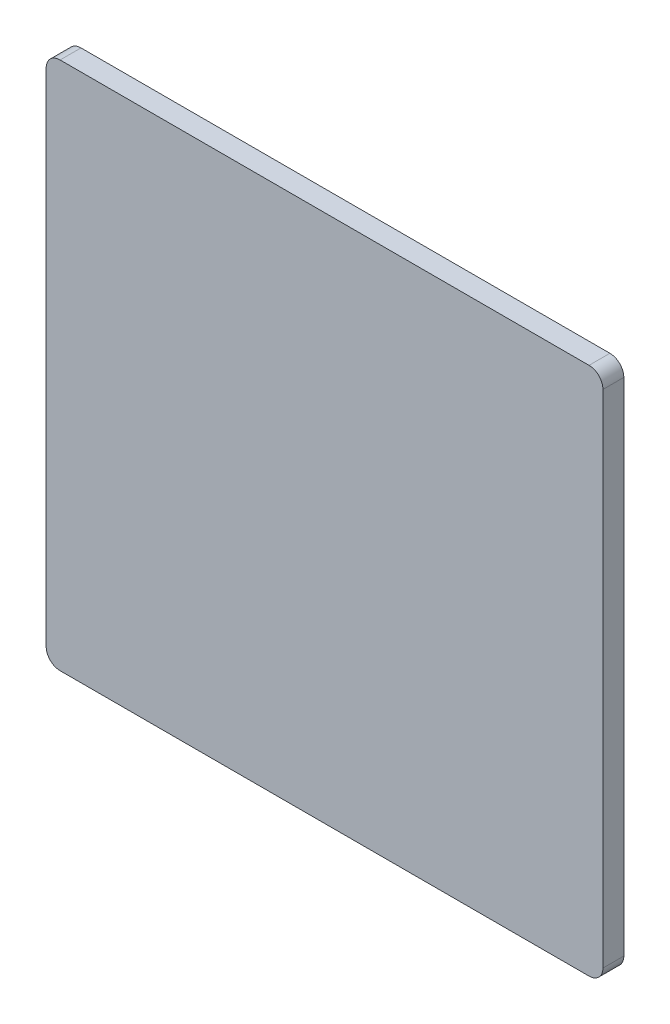
from build123d import *

# Parameters (mm, degrees)
SKETCH1_W           = 254
SKETCH1_H           = 241.3
BOSS_EXTRUDE1_DEPTH = 9.525
FILLET1_R           = 6.35


with BuildPart() as part:
    # Sketch1 → Boss-Extrude1 (new body)
    with BuildSketch(Plane.XY):
        Rectangle(SKETCH1_W, SKETCH1_H)
    extrude(amount=BOSS_EXTRUDE1_DEPTH)

    # Fillet1
    fillet1_edges = [part.edges().sort_by_distance(p)[0] for p in [
        (127, -120.65, 4.7625),
        (-127, -120.65, 4.7625),
        (-127, 120.65, 4.7625),
        (127, 120.65, 4.7625),
    ]]
    fillet(fillet1_edges, radius=FILLET1_R)


solid = part.part
